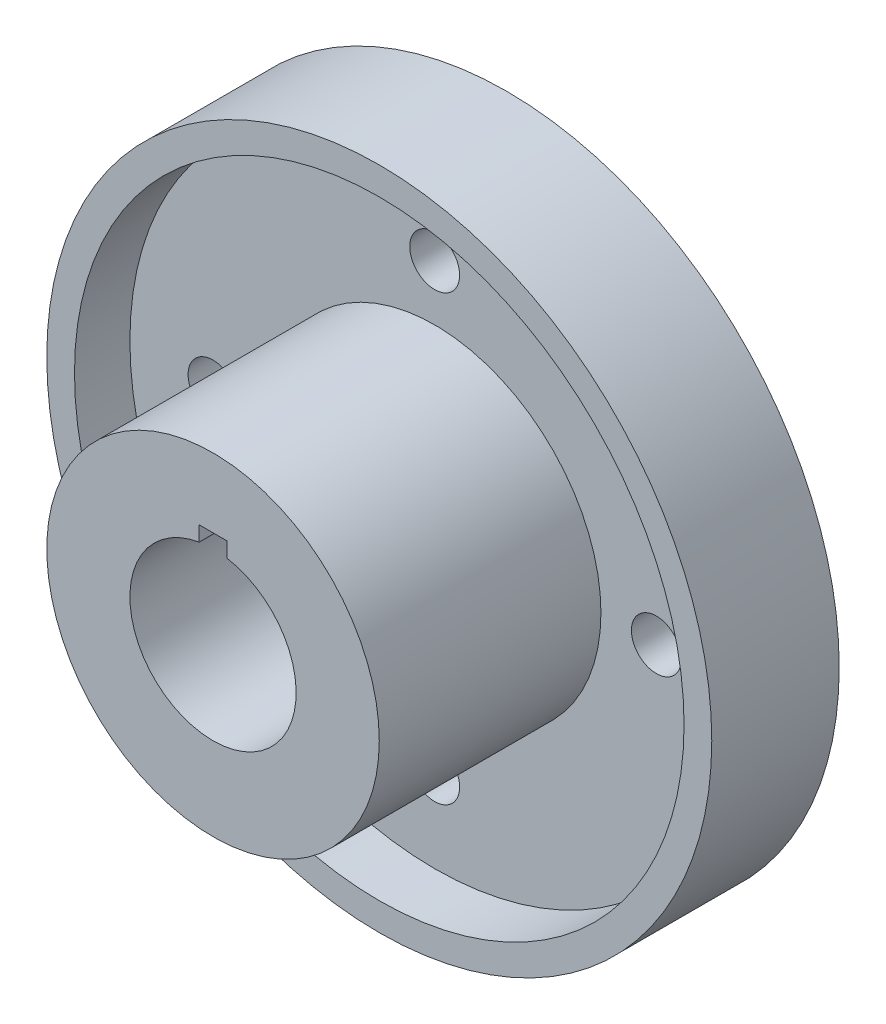
from build123d import *

# Parameters (mm, degrees)
SKETCH2_W            = 5
SKETCH2_H            = 5
CUT_EXTRUDE1_DEPTH   = 54
M8_CLEARANCE_HOLE2_D = 9
CIRPATTERN1_COUNT    = 4


with BuildPart() as part:
    # Sketch1 → Revolve1 (revolve)
    with BuildSketch(Plane(origin=(0, 0, 0), x_dir=(0, 0, -1), z_dir=(1, 0, 0))):
        Polygon((-3, 15), (-53, 15), (-53, 30), (-13, 30), (-13, 55), (-23, 55), (-23, 60), (0, 60), (0, 55), (-3, 55), (-3, 33.885514375), align=None)
    revolve(axis=Axis((0, 0, 0), (0, 0, -1)))

    # Sketch2 → Cut-Extrude1 (cut, through all)
    with BuildSketch(Plane.XY.offset(53)):
        with Locations((0, 15)):
            Rectangle(SKETCH2_W, SKETCH2_H)
    extrude(amount=-CUT_EXTRUDE1_DEPTH, mode=Mode.SUBTRACT)

    # M8 Clearance Hole2 (through all)
    with Locations(Plane.XY.offset(13)):
        with Locations((0, 40)):
            m8_clearance_hole2 = Hole(M8_CLEARANCE_HOLE2_D / 2)

    # CirPattern1: M8 Clearance Hole2 ×4 about axis
    cirpattern1_axis = Axis((0, 0, 0), (0, 0, 1))
    for i in range(1, CIRPATTERN1_COUNT):
        add(m8_clearance_hole2.rotate(cirpattern1_axis, i * 360 / CIRPATTERN1_COUNT), mode=Mode.SUBTRACT)


solid = part.part
